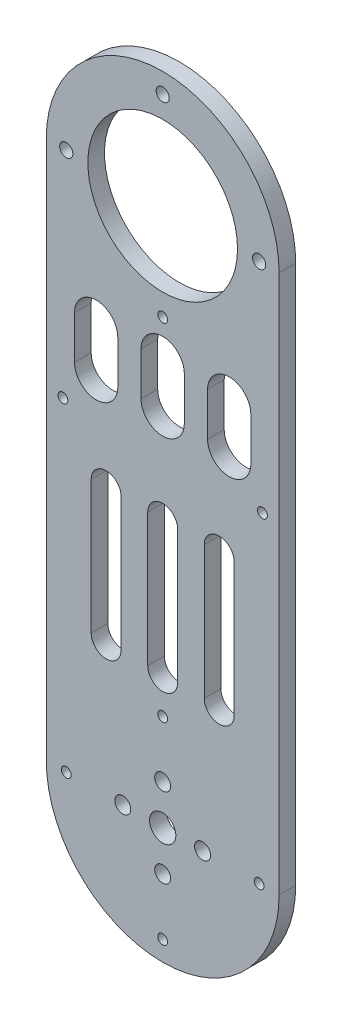
from build123d import *

# Parameters (mm, degrees)
SKETCH1_R           = 3.95
SKETCH1_R_2         = 1.475
SKETCH1_R_3         = 22.5
SKETCH1_R_4         = 2.4
SKETCH1_R_5         = 1.975
BOSS_EXTRUDE1_DEPTH = 5


with BuildPart() as part:
    # Sketch1 → Boss-Extrude1 (new body)
    with BuildSketch(Plane.XY):
        with BuildLine():
            Line((35, 0), (35, 162))
            ThreePointArc((35, 162), (0, 197), (-35, 162))
            Line((-35, 162), (-35, 0))
            ThreePointArc((-35, 0), (0, -35), (35, 0))
        make_face()
        Circle(SKETCH1_R, mode=Mode.SUBTRACT)
        with Locations((0, 29)):
            Circle(SKETCH1_R_2, mode=Mode.SUBTRACT)
        with Locations((0, 162)):
            Circle(SKETCH1_R_3, mode=Mode.SUBTRACT)
        with Locations((0, 133)):
            Circle(SKETCH1_R_2, mode=Mode.SUBTRACT)
        with Locations((-30, 97)):
            Circle(SKETCH1_R_2, mode=Mode.SUBTRACT)
        with Locations((30, 97)):
            Circle(SKETCH1_R_2, mode=Mode.SUBTRACT)
        with Locations((29, 0)):
            Circle(SKETCH1_R_2, mode=Mode.SUBTRACT)
        with Locations((0, -29)):
            Circle(SKETCH1_R_2, mode=Mode.SUBTRACT)
        with Locations((-29, 0)):
            Circle(SKETCH1_R_2, mode=Mode.SUBTRACT)
        with Locations((0, 12)):
            Circle(SKETCH1_R_4, mode=Mode.SUBTRACT)
        with Locations((12, 0)):
            Circle(SKETCH1_R_4, mode=Mode.SUBTRACT)
        with Locations((0, -12)):
            Circle(SKETCH1_R_4, mode=Mode.SUBTRACT)
        with Locations((-12, 0)):
            Circle(SKETCH1_R_4, mode=Mode.SUBTRACT)
        with Locations((0, 191)):
            Circle(SKETCH1_R_5, mode=Mode.SUBTRACT)
        with Locations((29, 162)):
            Circle(SKETCH1_R_5, mode=Mode.SUBTRACT)
        with Locations((-29, 162)):
            Circle(SKETCH1_R_5, mode=Mode.SUBTRACT)
        with BuildLine():
            Line((4.5, 80), (4.5, 40))
            ThreePointArc((4.5, 40), (0, 35.5), (-4.5, 40))
            Line((-4.5, 40), (-4.5, 80))
            ThreePointArc((-4.5, 80), (0, 84.5), (4.5, 80))
        make_face(mode=Mode.SUBTRACT)
        with BuildLine():
            Line((21.5, 80), (21.5, 40))
            ThreePointArc((21.5, 40), (17, 35.5), (12.5, 40))
            Line((12.5, 40), (12.5, 80))
            ThreePointArc((12.5, 80), (17, 84.5), (21.5, 80))
        make_face(mode=Mode.SUBTRACT)
        with BuildLine():
            Line((-21.5, 80), (-21.5, 40))
            ThreePointArc((-21.5, 40), (-17, 35.5), (-12.5, 40))
            Line((-12.5, 40), (-12.5, 80))
            ThreePointArc((-12.5, 80), (-17, 84.5), (-21.5, 80))
        make_face(mode=Mode.SUBTRACT)
        with BuildLine():
            Line((6.5, 121.5), (6.5, 108.5))
            ThreePointArc((6.5, 108.5), (0, 102), (-6.5, 108.5))
            Line((-6.5, 108.5), (-6.5, 121.5))
            ThreePointArc((-6.5, 121.5), (0, 128), (6.5, 121.5))
        make_face(mode=Mode.SUBTRACT)
        with BuildLine():
            Line((26.5, 120.946496324), (26.5, 107.946496324))
            ThreePointArc((26.5, 107.946496324), (20, 101.446496324), (13.5, 107.946496324))
            Line((13.5, 107.946496324), (13.5, 120.946496324))
            ThreePointArc((13.5, 120.946496324), (20, 127.446496324), (26.5, 120.946496324))
        make_face(mode=Mode.SUBTRACT)
        with BuildLine():
            Line((-26.5, 120.946496324), (-26.5, 107.946496324))
            ThreePointArc((-26.5, 107.946496324), (-20, 101.446496324), (-13.5, 107.946496324))
            Line((-13.5, 107.946496324), (-13.5, 120.946496324))
            ThreePointArc((-13.5, 120.946496324), (-20, 127.446496324), (-26.5, 120.946496324))
        make_face(mode=Mode.SUBTRACT)
    extrude(amount=BOSS_EXTRUDE1_DEPTH)


solid = part.part
